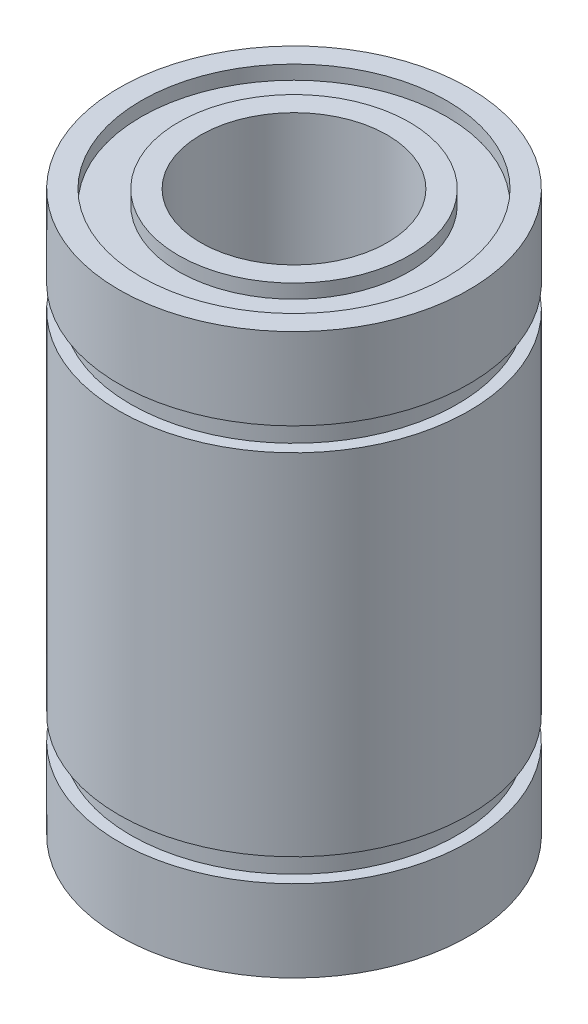
from build123d import *

# Parameters (mm, degrees)
ESQUISSE1_R        = 7.5
ESQUISSE1_R_2      = 4
BOSS_EXTRU_1_DEPTH = 12
ESQUISSE4_W        = 1
ESQUISSE4_H        = 1
ESQUISSE6_W        = 1.6
ESQUISSE6_H        = 1.2


with BuildPart() as part:
    # Esquisse1 → Boss.-Extru.1 (new body)
    with BuildSketch(Plane(origin=(0, 0, 0), x_dir=(1, 0, 0), z_dir=(0, 1, 0))):
        Circle(ESQUISSE1_R)
        Circle(ESQUISSE1_R_2, mode=Mode.SUBTRACT)
    extrude(amount=BOSS_EXTRU_1_DEPTH)

    # Enlèvement de matière-Balayage1: sweep along a path in Esquisse2
    with BuildLine(Plane(origin=(0, 4, 0), x_dir=(-1, 0, 0), z_dir=(0, -1, 0))) as enl_vement_de_mati_re_balayage1_path:
        CenterArc((0, 0), 7.5, 0, 360)
    # Esquisse4 → Enlèvement de matière-Balayage1 (sweep, cut)
    with BuildSketch(Plane.XY):
        with Locations((-7.5, 4)):
            Rectangle(ESQUISSE4_W, ESQUISSE4_H)
    sweep(path=enl_vement_de_mati_re_balayage1_path.line, mode=Mode.SUBTRACT)

    # Enlèvement de matière-Balayage2: sweep along a path in Esquisse5
    with BuildLine(Plane(origin=(0, 0, 0), x_dir=(-1, 0, 0), z_dir=(0, -1, 0))) as enl_vement_de_mati_re_balayage2_path:
        CenterArc((0, 0), 5.75, 0, 360)
    # Esquisse6 → Enlèvement de matière-Balayage2 (sweep, cut)
    with BuildSketch(Plane(origin=(0, 0, 0), x_dir=(0, 0, -1), z_dir=(1, 0, 0))):
        with Locations((5.75, 0)):
            Rectangle(ESQUISSE6_W, ESQUISSE6_H)
    sweep(path=enl_vement_de_mati_re_balayage2_path.line, mode=Mode.SUBTRACT)

    # Symétrie1: part across plane


with BuildPart() as part_1:
    add(part.part)
    add(part.part.mirror(Plane.ZX.offset(12)))


solid = part_1.part
